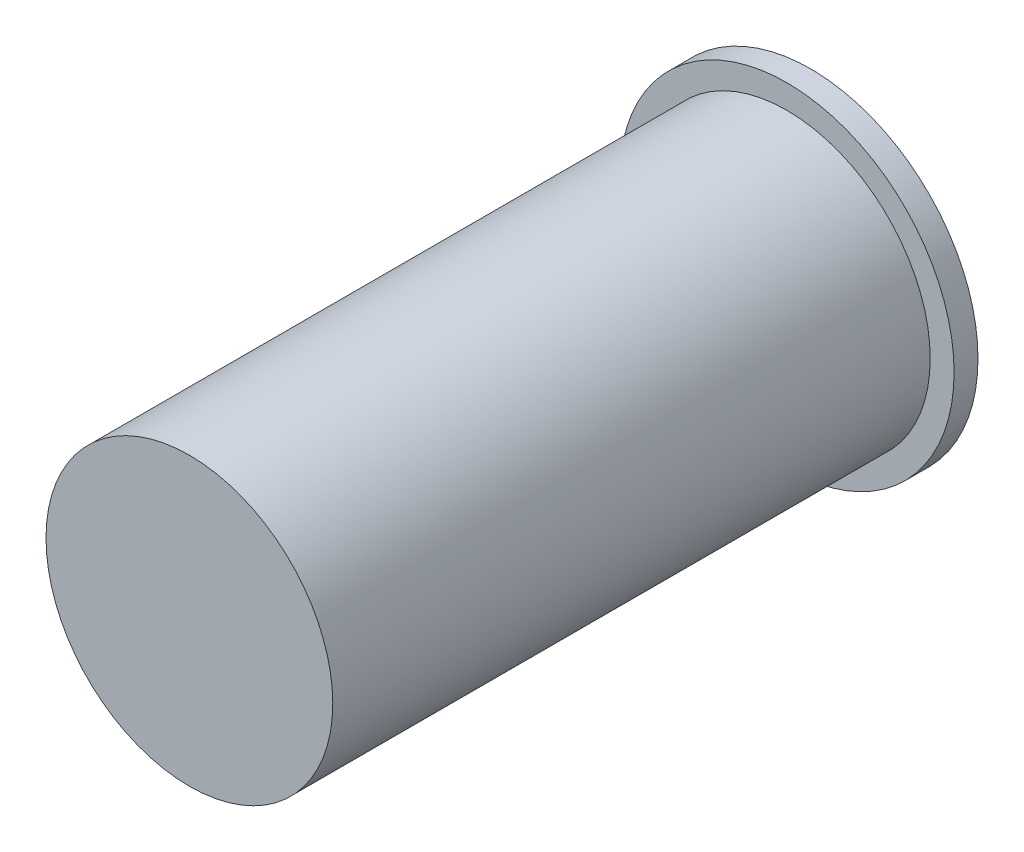
from build123d import *

# Parameters (mm, degrees)
SKETCH1_R           = 3.556
BOSS_EXTRUDE1_DEPTH = 0.508
SKETCH4_R           = 3.048
BOSS_EXTRUDE2_DEPTH = 12.7


with BuildPart() as part:
    # Sketch1 → Boss-Extrude1 (new body)
    with BuildSketch(Plane.XY):
        with Locations((-3.679284689, 5.512088214)):
            Circle(SKETCH1_R)
    extrude(amount=BOSS_EXTRUDE1_DEPTH)

    # Sketch4 → Boss-Extrude2 (add)
    with BuildSketch(Plane.XY.offset(0.508)):
        with Locations((-3.679284689, 5.512088214)):
            Circle(SKETCH4_R)
    extrude(amount=BOSS_EXTRUDE2_DEPTH)


solid = part.part
